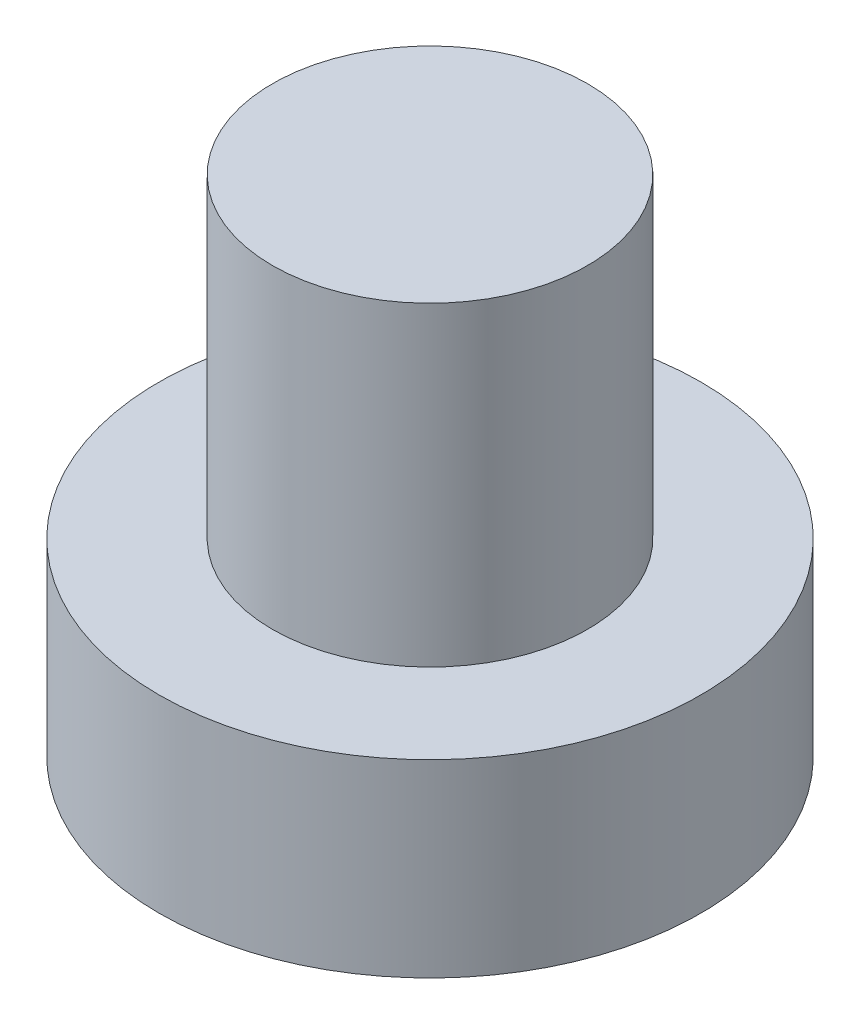
from build123d import *

# Parameters (mm, degrees)
SKETCH_1_R          = 4.3
EXTRUDE_1_DEPTH     = 3
SKETCH_2_R          = 2.5
EXTRUDE_2_DEPTH     = 5
CUT_EXTRUDE_1_DEPTH = 1.5


with BuildPart() as part:
    # 草图1 → 凸台-拉伸1 (new body)
    with BuildSketch(Plane(origin=(0, 0, 0), x_dir=(1, 0, 0), z_dir=(0, 1, 0))):
        Circle(SKETCH_1_R)
    extrude(amount=EXTRUDE_1_DEPTH)

    # 草图2 → 凸台-拉伸2 (add)
    with BuildSketch(Plane(origin=(0, 3, 0), x_dir=(1, 0, 0), z_dir=(0, 1, 0))):
        Circle(SKETCH_2_R)
    extrude(amount=EXTRUDE_2_DEPTH)

    # 草图3 → 切除-拉伸1 (cut)
    with BuildSketch(Plane.XZ):
        with BuildLine():
            Line((-0.6, 1.1), (-0.6, 2.4))
            Line((-0.6, 2.4), (0.6, 2.4))
            Line((0.6, 2.4), (0.6, 1.1))
            ThreePointArc((0.6, 1.1), (0.746446609, 0.746446609), (1.1, 0.6))
            Line((1.1, 0.6), (2.4, 0.6))
            Line((2.4, 0.6), (2.4, -0.6))
            Line((2.4, -0.6), (1.1, -0.6))
            ThreePointArc((1.1, -0.6), (0.746446609, -0.746446609), (0.6, -1.1))
            Line((0.6, -1.1), (0.6, -2.4))
            Line((0.6, -2.4), (-0.6, -2.4))
            Line((-0.6, -2.4), (-0.6, -1.1))
            ThreePointArc((-0.6, -1.1), (-0.746446609, -0.746446609), (-1.1, -0.6))
            Line((-1.1, -0.6), (-2.4, -0.6))
            Line((-2.4, -0.6), (-2.4, 0.6))
            Line((-2.4, 0.6), (-1.1, 0.6))
            ThreePointArc((-1.1, 0.6), (-0.746446609, 0.746446609), (-0.6, 1.1))
        make_face()
    extrude(amount=-CUT_EXTRUDE_1_DEPTH, mode=Mode.SUBTRACT)


solid = part.part
